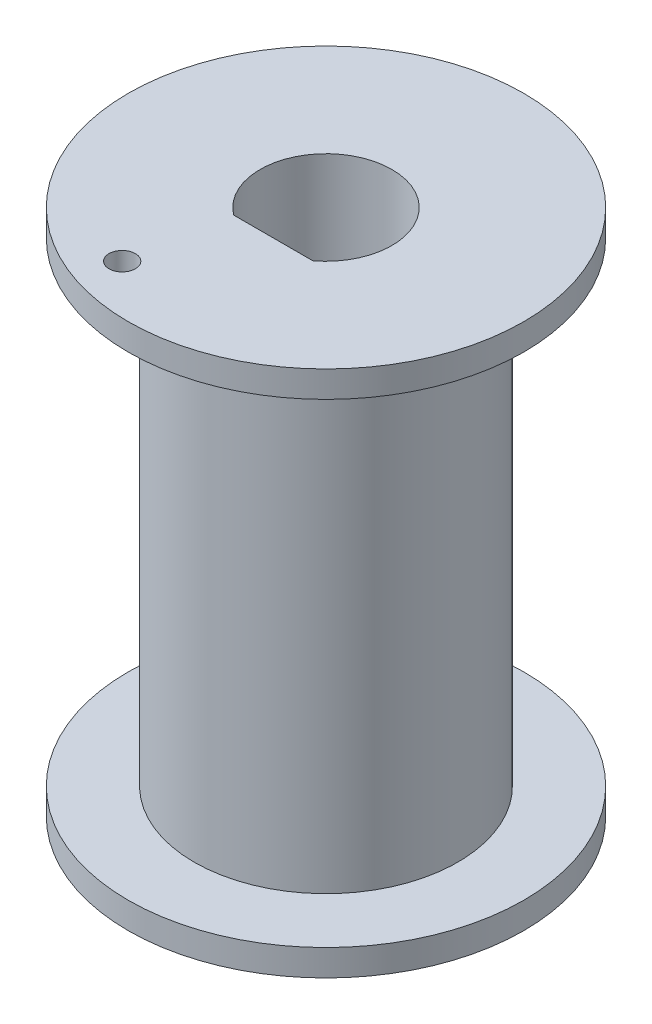
from build123d import *

# Parameters (mm, degrees)
SKETCH1_R           = 5
BOSS_EXTRUDE1_DEPTH = 20
SKETCH2_R           = 2.5
CUT_EXTRUDE1_DEPTH  = 21
BOSS_EXTRUDE2_DEPTH = 18
SKETCH5_R           = 7.5
SKETCH5_R_2         = 2.5
BOSS_EXTRUDE3_DEPTH = 1
SKETCH4_R           = 7.5
BOSS_EXTRUDE4_DEPTH = 1
SKETCH7_R           = 0.5
CUT_EXTRUDE2_DEPTH  = 2


with BuildPart() as part:
    # Sketch1 → Boss-Extrude1 (new body)
    with BuildSketch(Plane(origin=(0, 0, 0), x_dir=(1, 0, 0), z_dir=(0, 1, 0))):
        with Locations(Location((0, 0, 0), (0, 0, 270))):  # turned: the seam where the file's is
            Circle(SKETCH1_R)
    extrude(amount=BOSS_EXTRUDE1_DEPTH)

    # Sketch2 → Cut-Extrude1 (cut, through all)
    with BuildSketch(Plane(origin=(0, 20, 0), x_dir=(1, 0, 0), z_dir=(0, 1, 0))):
        with Locations(Location((0, 0, 0), (0, 0, 270))):  # turned: the seam where the file's is
            Circle(SKETCH2_R)
    extrude(amount=-CUT_EXTRUDE1_DEPTH, mode=Mode.SUBTRACT)

    # Sketch3 → Boss-Extrude2 (add)
    with BuildSketch(Plane(origin=(0, 20, 0), x_dir=(1, 0, 0), z_dir=(0, 1, 0))):
        with BuildLine():
            Line((1.5, -2), (-1.5, -2))
            ThreePointArc((-1.5, -2), (0, -2.5), (1.5, -2))
        make_face()
    extrude(amount=-BOSS_EXTRUDE2_DEPTH)

    # Sketch5 → Boss-Extrude3 (add)
    with BuildSketch(Plane.XZ):
        with Locations(Location((0, 0, 0), (0, 0, 270))):  # turned: the seam where the file's is
            Circle(SKETCH5_R)
        with Locations(Location((0, 0, 0), (0, 0, 90))):  # turned: the seam where the file's is
            Circle(SKETCH5_R_2, mode=Mode.SUBTRACT)
    extrude(amount=-BOSS_EXTRUDE3_DEPTH)

    # Sketch4 → Boss-Extrude4 (add)
    with BuildSketch(Plane(origin=(0, 20, 0), x_dir=(1, 0, 0), z_dir=(0, 1, 0))):
        with Locations(Location((0, 0, 0), (0, 0, 90))):  # turned: the seam where the file's is
            Circle(SKETCH4_R)
        with BuildLine():
            Line((1.5, -2), (-1.5, -2))
            ThreePointArc((-1.5, -2), (0, 2.5), (1.5, -2))
        make_face(mode=Mode.SUBTRACT)
    extrude(amount=-BOSS_EXTRUDE4_DEPTH)

    # Sketch7 → Cut-Extrude2 (cut, through all)
    with BuildSketch(Plane.XZ.offset(-19)):
        with Locations(Location((-2.100852557, 5.628196829, 0), (0, 0, 270))):  # turned: the seam where the file's is
            Circle(SKETCH7_R)
    extrude(amount=-CUT_EXTRUDE2_DEPTH, mode=Mode.SUBTRACT)


solid = part.part
